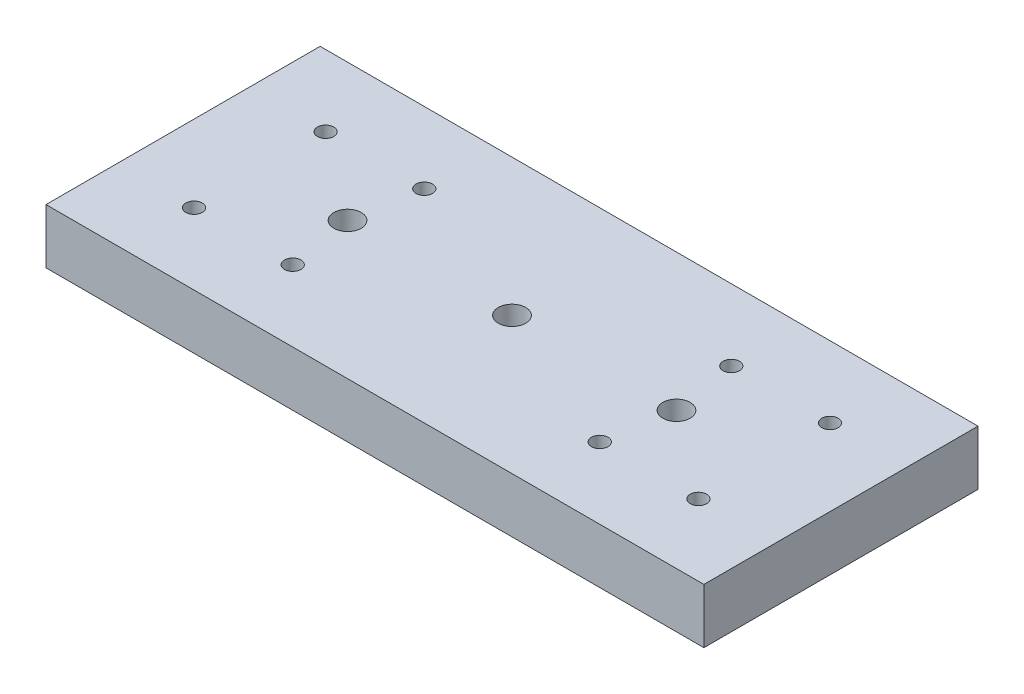
from build123d import *

# Parameters (mm, degrees)
SKETCH1_W           = 120
SKETCH1_H           = 50
BOSS_EXTRUDE1_DEPTH = 10
SKETCH2_R           = 1.5
CUT_EXTRUDE1_DEPTH  = 11
SKETCH3_R           = 2.5
CUT_EXTRUDE2_DEPTH  = 11
SKETCH4_R           = 4.25
CUT_EXTRUDE3_DEPTH  = 5


with BuildPart() as part:
    # Sketch1 → Boss-Extrude1 (new body)
    with BuildSketch(Plane(origin=(0, 0, 0), x_dir=(1, 0, 0), z_dir=(0, 1, 0))):
        Rectangle(SKETCH1_W, SKETCH1_H)
    extrude(amount=BOSS_EXTRUDE1_DEPTH)

    # Sketch2 → Cut-Extrude1 (cut, through all)
    with BuildSketch(Plane(origin=(0, 10, 0), x_dir=(1, 0, 0), z_dir=(0, 1, 0))):
        with Locations((28, -12)):
            Circle(SKETCH2_R)
        with Locations((28, 12)):
            Circle(SKETCH2_R)
        with Locations((46, -12)):
            Circle(SKETCH2_R)
        with Locations((46, 12)):
            Circle(SKETCH2_R)
        with Locations((-46, -12)):
            Circle(SKETCH2_R)
        with Locations((-46, 12)):
            Circle(SKETCH2_R)
        with Locations((-28, -12)):
            Circle(SKETCH2_R)
        with Locations((-28, 12)):
            Circle(SKETCH2_R)
    extrude(amount=-CUT_EXTRUDE1_DEPTH, mode=Mode.SUBTRACT)

    # Sketch3 → Cut-Extrude2 (cut, through all)
    with BuildSketch(Plane.XZ):
        Circle(SKETCH3_R)
        with Locations((30, 0)):
            Circle(SKETCH3_R)
        with Locations((-30, 0)):
            Circle(SKETCH3_R)
    extrude(amount=-CUT_EXTRUDE2_DEPTH, mode=Mode.SUBTRACT)

    # Sketch4 → Cut-Extrude3 (cut)
    with BuildSketch(Plane.XZ):
        with Locations((30, 0)):
            Circle(SKETCH4_R)
        Circle(SKETCH4_R)
        with Locations((-30, 0)):
            Circle(SKETCH4_R)
    extrude(amount=-CUT_EXTRUDE3_DEPTH, mode=Mode.SUBTRACT)


solid = part.part
